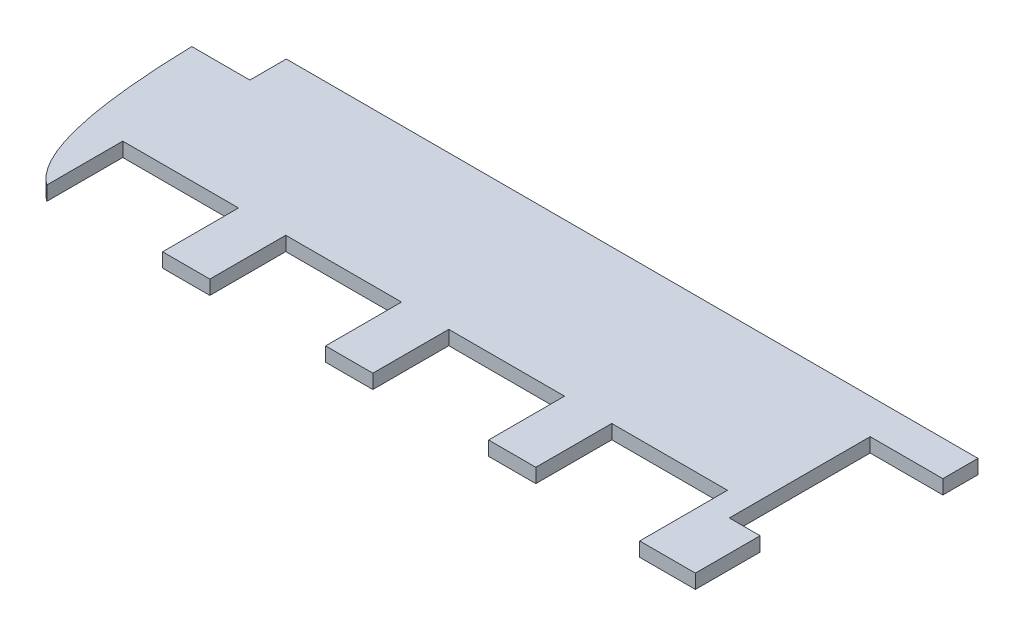
from build123d import *

# Parameters (mm, degrees)
BOSS_EXTRUDE1_DEPTH = 1.6


with BuildPart() as part:
    # Sketch1 → Boss-Extrude1 (new body)
    with BuildSketch(Plane(origin=(0, 0, 0), x_dir=(1, 0, 0), z_dir=(0, 1, 0))):
        with BuildLine():
            Line((-23.247910864, 15.801225627), (54.752089136, 15.801225627))
            Line((54.752089136, 15.801225627), (54.752089136, 11.841225627))
            Line((54.752089136, 11.841225627), (46.552089136, 11.841225627))
            Line((46.552089136, 11.841225627), (46.552089136, -4.038774373))
            Line((46.552089136, -4.038774373), (50.022089136, -4.038774373))
            Line((50.022089136, -4.038774373), (50.022089136, -11.338774373))
            Line((50.022089136, -11.338774373), (43.742089136, -11.338774373))
            Line((43.742089136, -11.338774373), (43.742089136, -1.438774373))
            Line((43.742089136, -1.438774373), (30.692089136, -1.438774373))
            Line((30.692089136, -1.438774373), (30.692089136, -9.998774373))
            Line((30.692089136, -9.998774373), (25.362089136, -9.998774373))
            Line((25.362089136, -9.998774373), (25.362089136, -1.438774373))
            Line((25.362089136, -1.438774373), (12.312089136, -1.438774373))
            Line((12.312089136, -1.438774373), (12.312089136, -9.998774373))
            Line((12.312089136, -9.998774373), (6.982089136, -9.998774373))
            Line((6.982089136, -9.998774373), (6.982089136, -1.438774373))
            Line((6.982089136, -1.438774373), (-6.067910864, -1.438774373))
            Line((-6.067910864, -1.438774373), (-6.067910864, -9.998774373))
            Line((-6.067910864, -9.998774373), (-11.397910864, -9.998774373))
            Line((-11.397910864, -9.998774373), (-11.397910864, -1.438774373))
            Line((-11.397910864, -1.438774373), (-24.447910864, -1.438774373))
            Line((-24.447910864, -1.438774373), (-24.447910864, -9.998774373))
            add(Edge.make_bspline(
                [(-24.447910864, -9.998774373), (-29.341121858, -6.518559079), (-29.797910864, 11.691225627)],
                knots=[0, 0, 0, 1, 1, 1], degree=2))
            Line((-29.797910864, 11.691225627), (-23.247910864, 11.691225627))
            Line((-23.247910864, 11.691225627), (-23.247910864, 15.801225627))
        make_face()
    extrude(amount=BOSS_EXTRUDE1_DEPTH)


solid = part.part
